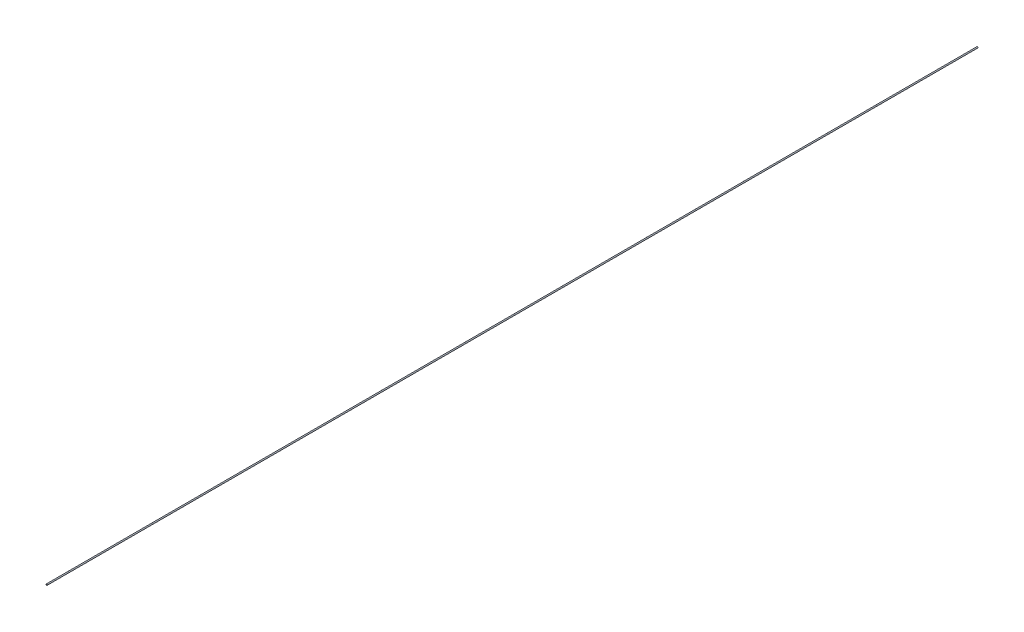
from build123d import *

# Parameters (mm, degrees)
SKETCH1_R           = 0.035
BOSS_EXTRUDE1_DEPTH = 55.9


with BuildPart() as part:
    # Sketch1 → Boss-Extrude1 (new body)
    with BuildSketch(Plane.XY):
        Circle(SKETCH1_R)
    extrude(amount=BOSS_EXTRUDE1_DEPTH)


solid = part.part
